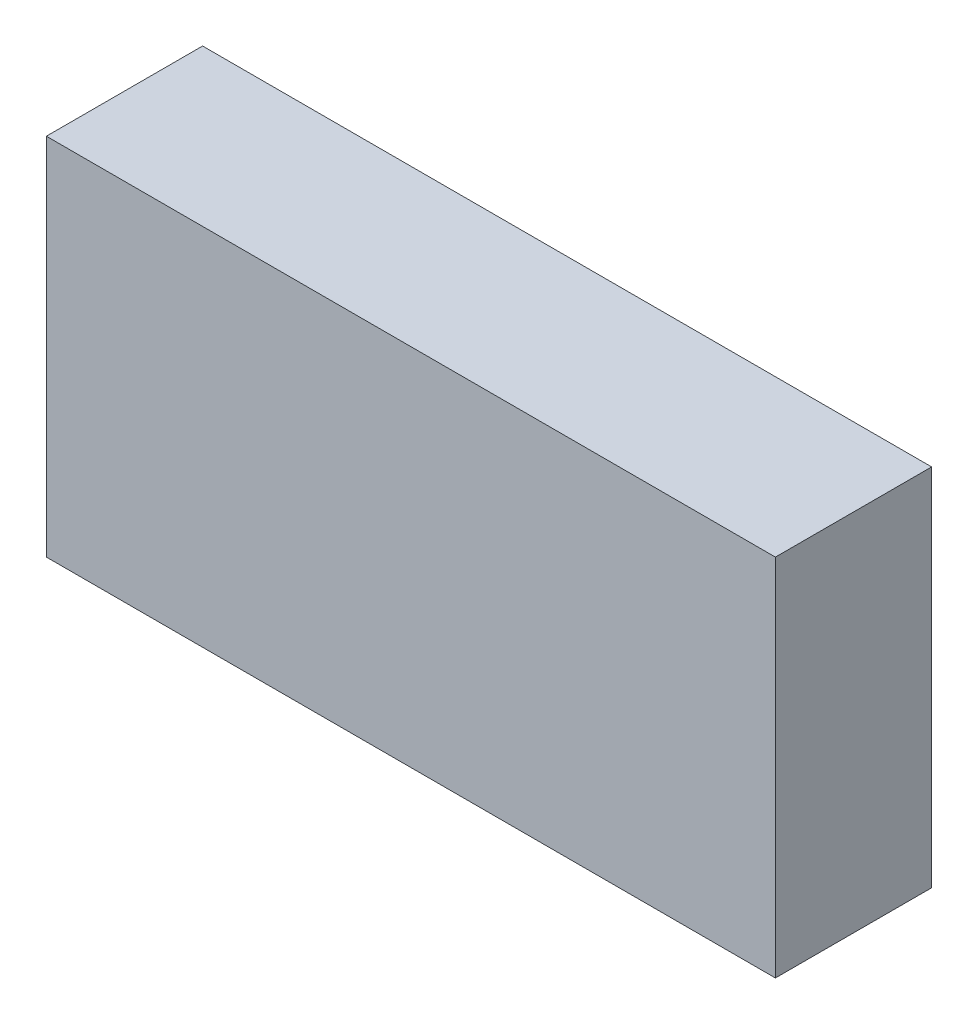
from build123d import *

# Parameters (mm, degrees)
SKETCH1_W           = 177.8
SKETCH1_H           = 88.9
BOSS_EXTRUDE1_DEPTH = 38.1


with BuildPart() as part:
    # Sketch1 → Boss-Extrude1 (new body)
    with BuildSketch(Plane.XY):
        Rectangle(SKETCH1_W, SKETCH1_H)
    extrude(amount=BOSS_EXTRUDE1_DEPTH)


solid = part.part
